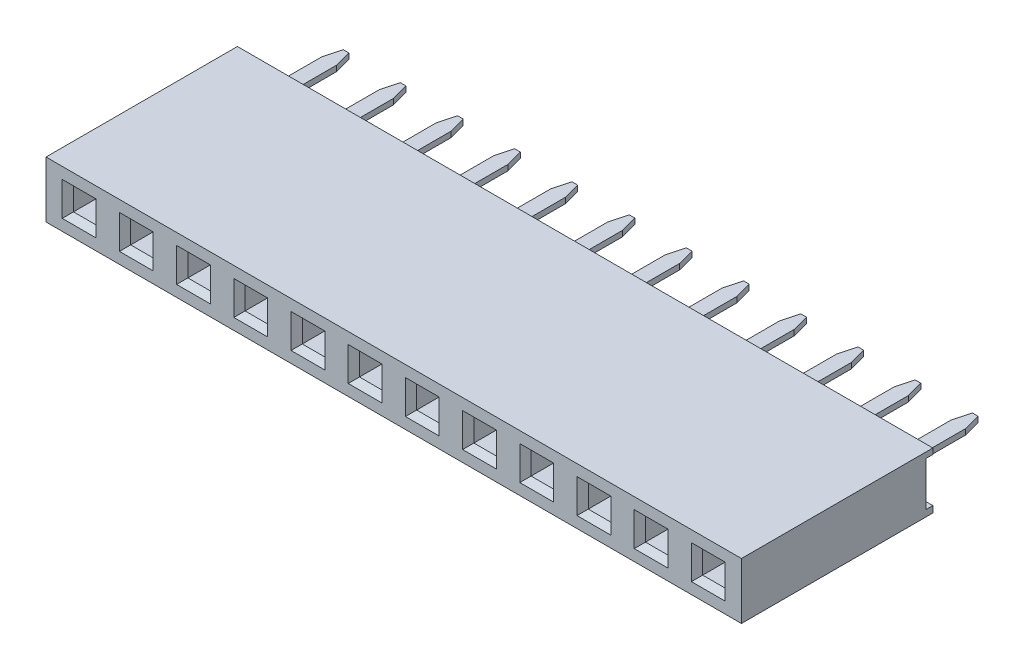
from build123d import *

# Parameters (mm, degrees)
SKETCH1_W                  = 30.88
SKETCH1_H                  = 2.5
BOSS_EXTRUDE1_DEPTH        = 8.5
SKETCH2_W                  = 1
SKETCH2_H                  = 1
CUT_EXTRUDE1_DEPTH         = 2.25
CHAMFER1_SIZE              = 0.25
SKETCH3_W                  = 0.3
SKETCH3_H                  = 1.963850618
CUT_EXTRUDE2_DEPTH         = 31.88
SKETCH4_W                  = 0.65
SKETCH4_H                  = 3.65
BOSS_EXTRUDE2_DEPTH        = 0.125
CHAMFER2_SIZE              = 0.2
CHAMFER2_SIZE2             = 0.746410162
LPATTERN4_COUNT            = 12
LPATTERN4_PITCH            = 2.54
LPATTERN5_COUNT            = 12
LPATTERN5_PITCH            = 2.54
CHAMFER1_OF_LPATTERN5_SIZE = 0.25


with BuildPart() as part:
    # Sketch1 → Boss-Extrude1 (new body)
    with BuildSketch(Plane.XY):
        with Locations((15.44, 1.25)):
            Rectangle(SKETCH1_W, SKETCH1_H)
    extrude(amount=BOSS_EXTRUDE1_DEPTH)

    # Sketch2 → Cut-Extrude1 (cut)
    with BuildSketch(Plane.XY.offset(8.5)):
        with Locations((1.47, 1.25)):
            Rectangle(SKETCH2_W, SKETCH2_H)
    cut_extrude1 = extrude(amount=-CUT_EXTRUDE1_DEPTH, mode=Mode.SUBTRACT)

    # Chamfer1
    chamfer1_edges = [part.edges().sort_by_distance(p)[0] for p in [
        (0.97, 1.25, 8.5),
        (1.47, 0.75, 8.5),
        (1.97, 1.25, 8.5),
        (1.47, 1.75, 8.5),
    ]]
    chamfer(chamfer1_edges, length=CHAMFER1_SIZE)

    # Sketch3 → Cut-Extrude2 (cut, through all)
    with BuildSketch(Plane.ZY):
        with Locations((0.15, 1.268074691)):
            Rectangle(SKETCH3_W, SKETCH3_H)
    extrude(amount=-CUT_EXTRUDE2_DEPTH, mode=Mode.SUBTRACT)

    # LPattern5: Cut-Extrude1 ×12
    with Locations(*[(i * LPATTERN5_PITCH, 0, 0) for i in range(1, LPATTERN5_COUNT)]):
        add(cut_extrude1, mode=Mode.SUBTRACT)

    # Chamfer1 of LPattern5
    chamfer1_of_lpattern5_edges = [part.edges().sort_by_distance(p)[0] for p in [
        (3.51, 1.25, 8.5),
        (4.01, 0.75, 8.5),
        (4.51, 1.25, 8.5),
        (4.01, 1.75, 8.5),
        (6.05, 1.25, 8.5),
        (6.55, 0.75, 8.5),
        (7.05, 1.25, 8.5),
        (6.55, 1.75, 8.5),
        (8.59, 1.25, 8.5),
        (9.09, 0.75, 8.5),
        (9.59, 1.25, 8.5),
        (9.09, 1.75, 8.5),
        (11.13, 1.25, 8.5),
        (11.63, 0.75, 8.5),
        (12.13, 1.25, 8.5),
        (11.63, 1.75, 8.5),
        (13.67, 1.25, 8.5),
        (14.17, 0.75, 8.5),
        (14.67, 1.25, 8.5),
        (14.17, 1.75, 8.5),
        (16.21, 1.25, 8.5),
        (16.71, 0.75, 8.5),
        (17.21, 1.25, 8.5),
        (16.71, 1.75, 8.5),
        (18.75, 1.25, 8.5),
        (19.25, 0.75, 8.5),
        (19.75, 1.25, 8.5),
        (19.25, 1.75, 8.5),
        (21.29, 1.25, 8.5),
        (21.79, 0.75, 8.5),
        (22.29, 1.25, 8.5),
        (21.79, 1.75, 8.5),
        (23.83, 1.25, 8.5),
        (24.33, 0.75, 8.5),
        (24.83, 1.25, 8.5),
        (24.33, 1.75, 8.5),
        (26.37, 1.25, 8.5),
        (26.87, 0.75, 8.5),
        (27.37, 1.25, 8.5),
        (26.87, 1.75, 8.5),
        (28.91, 1.25, 8.5),
        (29.41, 0.75, 8.5),
        (29.91, 1.25, 8.5),
        (29.41, 1.75, 8.5),
    ]]
    chamfer(chamfer1_of_lpattern5_edges, length=CHAMFER1_OF_LPATTERN5_SIZE)


with BuildPart() as body_2:
    # Sketch4 → Boss-Extrude2 (new body, symmetric)
    with BuildSketch(Plane(origin=(0, 1.25, 0), x_dir=(-1, 0, 0), z_dir=(0, -1, 0))):
        with Locations((-1.47, 1.525)):
            Rectangle(SKETCH4_W, SKETCH4_H)
    extrude(amount=BOSS_EXTRUDE2_DEPTH, both=True)

    # Chamfer2
    chamfer2_edges = [body_2.edges().sort_by_distance(p)[0] for p in [
        (1.795, 1.25, -3.35),
        (1.145, 1.25, -3.35),
    ]]
    chamfer2_side = [body_2.faces().sort_by_distance(p)[0] for p in [
        (1.47, 1.25, -3.35),
    ]]
    chamfer(chamfer2_edges, length=CHAMFER2_SIZE, length2=CHAMFER2_SIZE2, reference=chamfer2_side[0])


with BuildPart() as lpattern4_1:
    # LPattern4: pattern copy
    add(body_2.part.moved(Location(Vector(1, 0, 0) * (1 * LPATTERN4_PITCH))))


with BuildPart() as lpattern4_2:
    # LPattern4: pattern copy
    add(body_2.part.moved(Location(Vector(1, 0, 0) * (2 * LPATTERN4_PITCH))))


with BuildPart() as lpattern4_3:
    # LPattern4: pattern copy
    add(body_2.part.moved(Location(Vector(1, 0, 0) * (3 * LPATTERN4_PITCH))))


with BuildPart() as lpattern4_4:
    # LPattern4: pattern copy
    add(body_2.part.moved(Location(Vector(1, 0, 0) * (4 * LPATTERN4_PITCH))))


with BuildPart() as lpattern4_5:
    # LPattern4: pattern copy
    add(body_2.part.moved(Location(Vector(1, 0, 0) * (5 * LPATTERN4_PITCH))))


with BuildPart() as lpattern4_6:
    # LPattern4: pattern copy
    add(body_2.part.moved(Location(Vector(1, 0, 0) * (6 * LPATTERN4_PITCH))))


with BuildPart() as lpattern4_7:
    # LPattern4: pattern copy
    add(body_2.part.moved(Location(Vector(1, 0, 0) * (7 * LPATTERN4_PITCH))))


with BuildPart() as lpattern4_8:
    # LPattern4: pattern copy
    add(body_2.part.moved(Location(Vector(1, 0, 0) * (8 * LPATTERN4_PITCH))))


with BuildPart() as lpattern4_9:
    # LPattern4: pattern copy
    add(body_2.part.moved(Location(Vector(1, 0, 0) * (9 * LPATTERN4_PITCH))))


with BuildPart() as lpattern4_10:
    # LPattern4: pattern copy
    add(body_2.part.moved(Location(Vector(1, 0, 0) * (10 * LPATTERN4_PITCH))))


with BuildPart() as lpattern4_11:
    # LPattern4: pattern copy
    add(body_2.part.moved(Location(Vector(1, 0, 0) * (11 * LPATTERN4_PITCH))))


solid = Compound([part.part, body_2.part, lpattern4_1.part, lpattern4_2.part, lpattern4_3.part, lpattern4_4.part, lpattern4_5.part, lpattern4_6.part, lpattern4_7.part, lpattern4_8.part, lpattern4_9.part, lpattern4_10.part, lpattern4_11.part])
